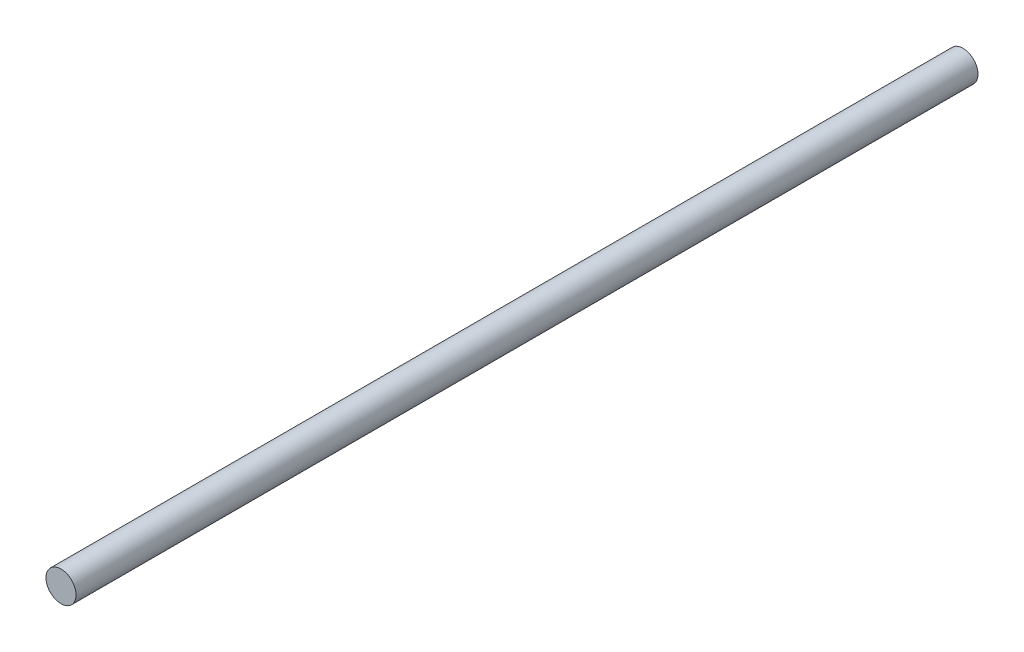
from build123d import *

# Parameters (mm, degrees)
ESBO_O1_R                = 3
RESSALTO_EXTRUS_O1_DEPTH = 180


with BuildPart() as part:
    # Esboço1 → Ressalto-extrusão1 (new body)
    with BuildSketch(Plane.XY):
        Circle(ESBO_O1_R)
    extrude(amount=RESSALTO_EXTRUS_O1_DEPTH)


solid = part.part
